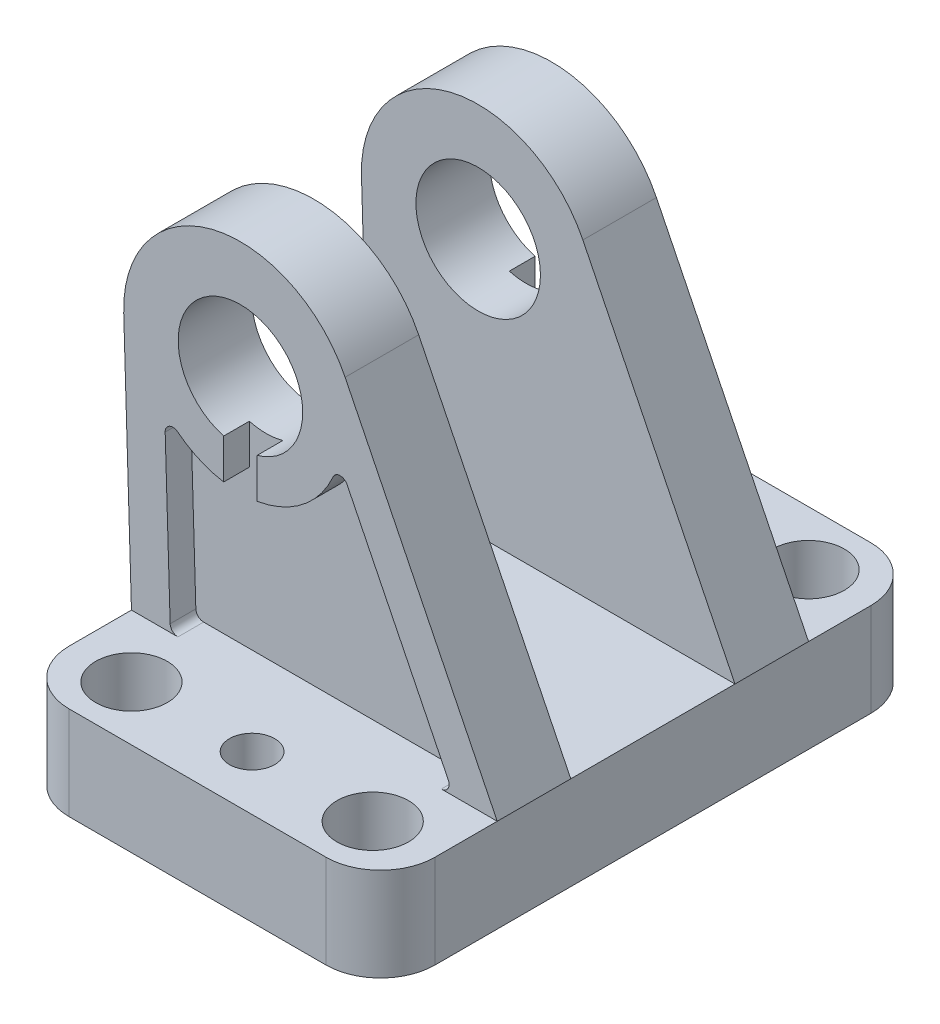
from build123d import *

# Parameters (mm, degrees)
SKETCH1_R               = 4.6
SKETCH1_R_2             = 2.9
BOSS_EXTRUDE1_DEPTH     = 12
CUT_EXTRUDE1_DEPTH      = 6
SKETCH3_R               = 8
BOSS_EXTRUDE2_DEPTH     = 9.45
CUT_EXTRUDE2_DEPTH      = 3.3
SKETCH5_R               = 8
BOSS_EXTRUDE3_DEPTH     = 9.45
CUT_EXTRUDE3_DEPTH      = 3.3
CUT_EXTRUDE4_DEPTH      = 3.3
CUT_EXTRUDE4_DEPTH_BACK = 3.3
CUT_EXTRUDE5_DEPTH      = 3.3
CUT_EXTRUDE5_DEPTH_BACK = 3.3


with BuildPart() as part:
    # Sketch1 → Boss-Extrude1 (new body)
    with BuildSketch(Plane(origin=(0, 0, 0), x_dir=(1, 0, 0), z_dir=(0, 1, 0))):
        with BuildLine():
            Line((-16.5, -35), (16.5, -35))
            ThreePointArc((16.5, -35), (21.449747468, -32.949747468), (23.5, -28))
            Line((23.5, -28), (23.5, 28))
            ThreePointArc((23.5, 28), (21.449747468, 32.949747468), (16.5, 35))
            Line((16.5, 35), (-16.5, 35))
            ThreePointArc((-16.5, 35), (-21.449747468, 32.949747468), (-23.5, 28))
            Line((-23.5, 28), (-23.5, -28))
            ThreePointArc((-23.5, -28), (-21.449747468, -32.949747468), (-16.5, -35))
        make_face()
        with Locations((15.5, 28)):
            Circle(SKETCH1_R, mode=Mode.SUBTRACT)
        with Locations((15.5, -28)):
            Circle(SKETCH1_R, mode=Mode.SUBTRACT)
        with Locations((0, 28)):
            Circle(SKETCH1_R_2, mode=Mode.SUBTRACT)
        with Locations((0, -28)):
            Circle(SKETCH1_R_2, mode=Mode.SUBTRACT)
        with Locations((-15.5, 28)):
            Circle(SKETCH1_R, mode=Mode.SUBTRACT)
        with Locations((-15.5, -28)):
            Circle(SKETCH1_R, mode=Mode.SUBTRACT)
    extrude(amount=BOSS_EXTRUDE1_DEPTH)

    # Sketch2 → Cut-Extrude1 (cut)
    with BuildSketch(Plane(origin=(0, 0, 0), x_dir=(1, 0, 0), z_dir=(0, 1, 0))):
        with BuildLine():
            Line((-8.006002402, -23), (8.006002402, -23))
            ThreePointArc((8.006002402, -23), (8.439015104, -22.901387819), (8.786627152, -22.625))
            ThreePointArc((8.786627152, -22.625), (12.608534281, -19.900652743), (17.291666667, -19.588702207))
            ThreePointArc((17.291666667, -19.588702207), (18.12915287, -19.387925912), (18.5, -18.610644325))
            Line((18.5, -18.610644325), (18.5, 18.610644325))
            ThreePointArc((18.5, 18.610644325), (18.129152893, 19.387925893), (17.291666727, 19.58870222))
            ThreePointArc((17.291666727, 19.58870222), (12.60853431, 19.900652732), (8.786627152, 22.625))
            ThreePointArc((8.786627152, 22.625), (8.439015104, 22.901387819), (8.006002402, 23))
            Line((8.006002402, 23), (-8.006002402, 23))
            ThreePointArc((-8.006002402, 23), (-8.439015104, 22.901387819), (-8.786627152, 22.625))
            ThreePointArc((-8.786627152, 22.625), (-12.608534281, 19.900652743), (-17.291666667, 19.588702207))
            ThreePointArc((-17.291666667, 19.588702207), (-18.12915287, 19.387925912), (-18.5, 18.610644325))
            Line((-18.5, 18.610644325), (-18.5, -18.610644325))
            ThreePointArc((-18.5, -18.610644325), (-18.129152893, -19.387925893), (-17.291666727, -19.58870222))
            ThreePointArc((-17.291666727, -19.58870222), (-12.60853431, -19.900652732), (-8.786627152, -22.625))
            ThreePointArc((-8.786627152, -22.625), (-8.439015104, -22.901387819), (-8.006002402, -23))
        make_face()
    extrude(amount=CUT_EXTRUDE1_DEPTH, mode=Mode.SUBTRACT)

    # Sketch3 → Boss-Extrude2 (add)
    with BuildSketch(Plane.XY.offset(20)):
        with BuildLine():
            Line((-24.493021315, 44.542493891), (-23.5, 12))
            Line((-23.5, 12), (23.5, 12))
            Line((23.5, 12), (3.952899906, 51.634718088))
            ThreePointArc((3.952899906, 51.634718088), (-13.128760739, 59.554452772), (-24.493021315, 44.542493891))
        make_face()
        with Locations((-9.5, 45)):
            Circle(SKETCH3_R, mode=Mode.SUBTRACT)
    extrude(amount=-BOSS_EXTRUDE2_DEPTH)

    # Sketch4 → Cut-Extrude2 (cut)
    with BuildSketch(Plane.XY.offset(20)):
        with BuildLine():
            Line((-19.168267115, 33.976179837), (-18.527256585, 12.969499593))
            ThreePointArc((-18.527256585, 12.969499593), (-18.223961586, 12.282190691), (-17.527721831, 12))
            Line((-17.527721831, 12), (16.316811337, 12))
            ThreePointArc((16.316811337, 12), (17.166021129, 12.471944387), (17.213671331, 13.442314539))
            Line((17.213671331, 13.442314539), (4.211894935, 39.805393442))
            ThreePointArc((4.211894935, 39.805393442), (3.293145866, 40.362839309), (2.399675303, 39.765716124))
            ThreePointArc((2.399675303, 39.765716124), (-6.355074026, 32.386140931), (-17.549537192, 34.791917369))
            ThreePointArc((-17.549537192, 34.791917369), (-18.618756227, 34.899696772), (-19.168267115, 33.976179837))
        make_face()
    extrude(amount=-CUT_EXTRUDE2_DEPTH, mode=Mode.SUBTRACT)

    # Sketch5 → Boss-Extrude3 (add)
    with BuildSketch(Plane.XY.offset(-20)):
        with BuildLine():
            Line((-24.493021315, 44.542493891), (-23.5, 12))
            Line((-23.5, 12), (23.5, 12))
            Line((23.5, 12), (3.952899906, 51.634718088))
            ThreePointArc((3.952899906, 51.634718088), (-13.128760739, 59.554452772), (-24.493021315, 44.542493891))
        make_face()
        with Locations((-9.5, 45)):
            Circle(SKETCH5_R, mode=Mode.SUBTRACT)
    extrude(amount=BOSS_EXTRUDE3_DEPTH)

    # Sketch6 → Cut-Extrude3 (cut)
    with BuildSketch(Plane.XY.offset(-20)):
        with BuildLine():
            Line((-19.168267115, 33.976179837), (-18.527256585, 12.969499593))
            ThreePointArc((-18.527256585, 12.969499593), (-18.223961586, 12.282190691), (-17.527721831, 12))
            Line((-17.527721831, 12), (16.316811337, 12))
            ThreePointArc((16.316811337, 12), (17.166021129, 12.471944387), (17.213671331, 13.442314539))
            Line((17.213671331, 13.442314539), (4.211894935, 39.805393442))
            ThreePointArc((4.211894935, 39.805393442), (3.293145866, 40.362839309), (2.399675303, 39.765716124))
            ThreePointArc((2.399675303, 39.765716124), (-6.355074026, 32.386140931), (-17.549537192, 34.791917369))
            ThreePointArc((-17.549537192, 34.791917369), (-18.618756227, 34.899696772), (-19.168267115, 33.976179837))
        make_face()
    extrude(amount=CUT_EXTRUDE3_DEPTH, mode=Mode.SUBTRACT)

    # Sketch7 → Cut-Extrude4 (cut, two sides)
    with BuildSketch(Plane.XY.offset(20)) as cut_extrude4_sk:
        with BuildLine():
            Line((-7.35, 30.15), (-7.35, 45))
            Line((-7.35, 45), (-11.65, 45))
            Line((-11.65, 45), (-11.65, 30.15))
            ThreePointArc((-11.65, 30.15), (-9.5, 28), (-7.35, 30.15))
        make_face()
    extrude(amount=CUT_EXTRUDE4_DEPTH, mode=Mode.SUBTRACT)
    extrude(cut_extrude4_sk.sketch, amount=-CUT_EXTRUDE4_DEPTH_BACK, mode=Mode.SUBTRACT)

    # Sketch8 → Cut-Extrude5 (cut, two sides)
    with BuildSketch(Plane.XY.offset(-20)) as cut_extrude5_sk:
        with BuildLine():
            Line((-7.35, 30.15), (-7.35, 45))
            Line((-7.35, 45), (-11.65, 45))
            Line((-11.65, 45), (-11.65, 30.15))
            ThreePointArc((-11.65, 30.15), (-9.5, 28), (-7.35, 30.15))
        make_face()
    extrude(amount=CUT_EXTRUDE5_DEPTH, mode=Mode.SUBTRACT)
    extrude(cut_extrude5_sk.sketch, amount=-CUT_EXTRUDE5_DEPTH_BACK, mode=Mode.SUBTRACT)


solid = part.part
